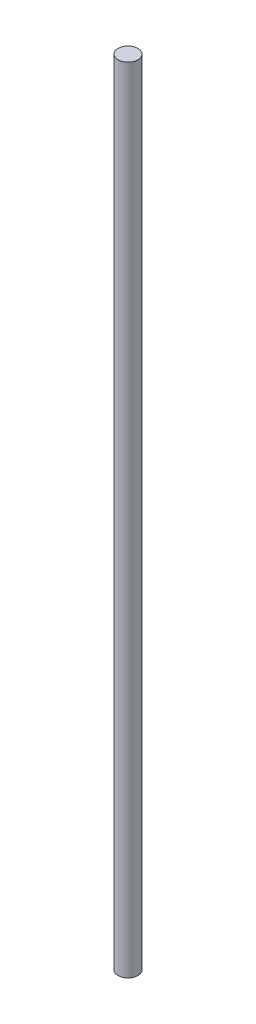
from build123d import *

# Parameters (mm, degrees)
SKETCH1_R           = 3.175
BOSS_EXTRUDE1_DEPTH = 127


with BuildPart() as part:
    # Sketch1 → Boss-Extrude1 (new body, symmetric)
    with BuildSketch(Plane(origin=(0, 0, 0), x_dir=(1, 0, 0), z_dir=(0, 1, 0))):
        Circle(SKETCH1_R)
    extrude(amount=BOSS_EXTRUDE1_DEPTH, both=True)


solid = part.part
